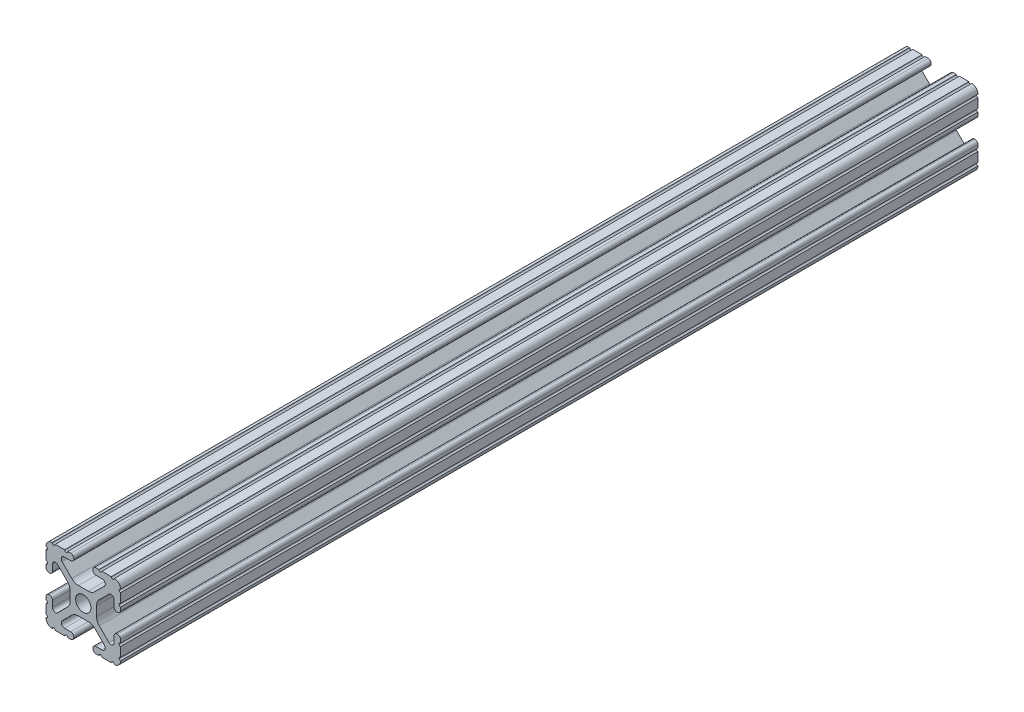
from build123d import *

# Parameters (mm, degrees)
SKETCH1_R           = 2.6035
BOSS_EXTRUDE1_DEPTH = 146.05


with BuildPart() as part:
    # Sketch1 → Boss-Extrude1 (new body, symmetric)
    with BuildSketch(Plane.XY):
        with BuildLine():
            Line((-7.179650497, -8.645192506), (-3.952270251, -5.423690499))
            ThreePointArc((-3.952270251, -5.423690499), (-2.922936451, -4.736929036), (-1.709253557, -4.4958))
            Line((-1.709253557, -4.4958), (1.709253557, -4.4958))
            ThreePointArc((1.709253557, -4.4958), (2.922936451, -4.736929036), (3.952270251, -5.423690499))
            Line((3.952270251, -5.423690499), (7.179650497, -8.645192506))
            ThreePointArc((7.179650497, -8.645192506), (7.41473083, -9.822813117), (6.416408329, -10.4902))
            Line((6.416408329, -10.4902), (4.287512407, -10.4902))
            ThreePointArc((4.287512407, -10.4902), (3.54574862, -10.79744862), (3.2385, -11.539212407))
            Line((3.2385, -11.539212407), (3.2385, -11.650987593))
            ThreePointArc((3.2385, -11.650987593), (3.54574862, -12.39275138), (4.287512407, -12.7))
            Line((4.287512407, -12.7), (5.317126718, -12.7))
            ThreePointArc((5.317126718, -12.7), (5.825126718, -12.192), (6.333126718, -12.7))
            Line((6.333126718, -12.7), (9.550443118, -12.7))
            ThreePointArc((9.550443118, -12.7), (10.058366869, -12.192000006), (10.566443095, -12.699847501))
            ThreePointArc((10.566443095, -12.699847501), (12.082537762, -12.08250727), (12.699846982, -10.566399977))
            ThreePointArc((12.699846982, -10.566399977), (12.192000006, -10.058323491), (12.7, -9.5504))
            Line((12.7, -9.5504), (12.7, -6.3330836))
            ThreePointArc((12.7, -6.3330836), (12.192, -5.8250836), (12.7, -5.3170836))
            Line((12.7, -5.3170836), (12.7, -4.287469289))
            ThreePointArc((12.7, -4.287469289), (12.39275138, -3.545705502), (11.650987593, -3.238456882))
            Line((11.650987593, -3.238456882), (11.539212407, -3.238456882))
            ThreePointArc((11.539212407, -3.238456882), (10.79744862, -3.545705502), (10.4902, -4.287469289))
            Line((10.4902, -4.287469289), (10.4902, -6.402089023))
            ThreePointArc((10.4902, -6.402089023), (9.856505071, -7.351067942), (8.737131347, -7.129408934))
            Line((8.737131347, -7.129408934), (5.441005833, -3.840816462))
            ThreePointArc((5.441005833, -3.840816462), (4.750877967, -2.809883091), (4.5085, -1.593185507))
            Line((4.5085, -1.593185507), (4.5085, 1.593185507))
            ThreePointArc((4.5085, 1.593185507), (4.750877967, 2.809883091), (5.441005833, 3.840816462))
            Line((5.441005833, 3.840816462), (8.737131347, 7.129408934))
            ThreePointArc((8.737131347, 7.129408934), (9.856505071, 7.351067942), (10.4902, 6.402089023))
            Line((10.4902, 6.402089023), (10.4902, 4.287469289))
            ThreePointArc((10.4902, 4.287469289), (10.79744862, 3.545705502), (11.539212407, 3.238456882))
            Line((11.539212407, 3.238456882), (11.650987593, 3.238456882))
            ThreePointArc((11.650987593, 3.238456882), (12.39275138, 3.545705502), (12.7, 4.287469289))
            Line((12.7, 4.287469289), (12.7, 5.3170836))
            ThreePointArc((12.7, 5.3170836), (12.192, 5.8250836), (12.7, 6.3330836))
            Line((12.7, 6.3330836), (12.7, 9.5504))
            ThreePointArc((12.7, 9.5504), (12.192000006, 10.058323491), (12.699846982, 10.566399977))
            ThreePointArc((12.699846982, 10.566399977), (12.082537762, 12.08250727), (10.566443095, 12.699847501))
            ThreePointArc((10.566443095, 12.699847501), (10.058366869, 12.192000006), (9.550443118, 12.7))
            Line((9.550443118, 12.7), (6.333126718, 12.7))
            ThreePointArc((6.333126718, 12.7), (5.825126718, 12.192), (5.317126718, 12.7))
            Line((5.317126718, 12.7), (4.287512407, 12.7))
            ThreePointArc((4.287512407, 12.7), (3.54574862, 12.39275138), (3.2385, 11.650987593))
            Line((3.2385, 11.650987593), (3.2385, 11.539212407))
            ThreePointArc((3.2385, 11.539212407), (3.54574862, 10.79744862), (4.287512407, 10.4902))
            Line((4.287512407, 10.4902), (6.476788598, 10.4902))
            ThreePointArc((6.476788598, 10.4902), (7.432222385, 9.85140422), (7.207036008, 8.724370562))
            Line((7.207036008, 8.724370562), (3.898272566, 5.423169045))
            ThreePointArc((3.898272566, 5.423169045), (2.869120213, 4.736787962), (1.655778399, 4.4958))
            Line((1.655778399, 4.4958), (-1.655778399, 4.4958))
            ThreePointArc((-1.655778399, 4.4958), (-2.869120213, 4.736787962), (-3.898272566, 5.423169045))
            Line((-3.898272566, 5.423169045), (-7.207036008, 8.724370562))
            ThreePointArc((-7.207036008, 8.724370562), (-7.432222385, 9.85140422), (-6.476788598, 10.4902))
            Line((-6.476788598, 10.4902), (-4.287512407, 10.4902))
            ThreePointArc((-4.287512407, 10.4902), (-3.54574862, 10.79744862), (-3.2385, 11.539212407))
            Line((-3.2385, 11.539212407), (-3.2385, 11.650987593))
            ThreePointArc((-3.2385, 11.650987593), (-3.54574862, 12.39275138), (-4.287512407, 12.7))
            Line((-4.287512407, 12.7), (-5.317126718, 12.7))
            ThreePointArc((-5.317126718, 12.7), (-5.825126718, 12.192), (-6.333126718, 12.7))
            Line((-6.333126718, 12.7), (-9.550443118, 12.7))
            ThreePointArc((-9.550443118, 12.7), (-10.058366869, 12.192000006), (-10.566443095, 12.699847501))
            ThreePointArc((-10.566443095, 12.699847501), (-12.082537762, 12.08250727), (-12.699846982, 10.566399977))
            ThreePointArc((-12.699846982, 10.566399977), (-12.192000006, 10.058323491), (-12.7, 9.5504))
            Line((-12.7, 9.5504), (-12.7, 6.3330836))
            ThreePointArc((-12.7, 6.3330836), (-12.192, 5.8250836), (-12.7, 5.3170836))
            Line((-12.7, 5.3170836), (-12.7, 4.287469289))
            ThreePointArc((-12.7, 4.287469289), (-12.39275138, 3.545705502), (-11.650987593, 3.238456882))
            Line((-11.650987593, 3.238456882), (-11.539212407, 3.238456882))
            ThreePointArc((-11.539212407, 3.238456882), (-10.79744862, 3.545705502), (-10.4902, 4.287469289))
            Line((-10.4902, 4.287469289), (-10.4902, 6.402089023))
            ThreePointArc((-10.4902, 6.402089023), (-9.856505071, 7.351067942), (-8.737131347, 7.129408934))
            Line((-8.737131347, 7.129408934), (-5.441005833, 3.840816462))
            ThreePointArc((-5.441005833, 3.840816462), (-4.750877967, 2.809883091), (-4.5085, 1.593185507))
            Line((-4.5085, 1.593185507), (-4.5085, -1.593185507))
            ThreePointArc((-4.5085, -1.593185507), (-4.750877967, -2.809883091), (-5.441005833, -3.840816462))
            Line((-5.441005833, -3.840816462), (-8.737131347, -7.129408934))
            ThreePointArc((-8.737131347, -7.129408934), (-9.856505071, -7.351067942), (-10.4902, -6.402089023))
            Line((-10.4902, -6.402089023), (-10.4902, -4.287469289))
            ThreePointArc((-10.4902, -4.287469289), (-10.79744862, -3.545705502), (-11.539212407, -3.238456882))
            Line((-11.539212407, -3.238456882), (-11.650987593, -3.238456882))
            ThreePointArc((-11.650987593, -3.238456882), (-12.39275138, -3.545705502), (-12.7, -4.287469289))
            Line((-12.7, -4.287469289), (-12.7, -5.3170836))
            ThreePointArc((-12.7, -5.3170836), (-12.192, -5.8250836), (-12.7, -6.3330836))
            Line((-12.7, -6.3330836), (-12.7, -9.5504))
            ThreePointArc((-12.7, -9.5504), (-12.192000006, -10.058323491), (-12.699846982, -10.566399977))
            ThreePointArc((-12.699846982, -10.566399977), (-12.082537762, -12.08250727), (-10.566443095, -12.699847501))
            ThreePointArc((-10.566443095, -12.699847501), (-10.058366869, -12.192000006), (-9.550443118, -12.7))
            Line((-9.550443118, -12.7), (-6.333126718, -12.7))
            ThreePointArc((-6.333126718, -12.7), (-5.825126718, -12.192), (-5.317126718, -12.7))
            Line((-5.317126718, -12.7), (-4.287512407, -12.7))
            ThreePointArc((-4.287512407, -12.7), (-3.54574862, -12.39275138), (-3.2385, -11.650987593))
            Line((-3.2385, -11.650987593), (-3.2385, -11.539212407))
            ThreePointArc((-3.2385, -11.539212407), (-3.54574862, -10.79744862), (-4.287512407, -10.4902))
            Line((-4.287512407, -10.4902), (-6.416408329, -10.4902))
            ThreePointArc((-6.416408329, -10.4902), (-7.41473083, -9.822813117), (-7.179650497, -8.645192506))
        make_face()
        Circle(SKETCH1_R, mode=Mode.SUBTRACT)
    extrude(amount=BOSS_EXTRUDE1_DEPTH, both=True)


solid = part.part
